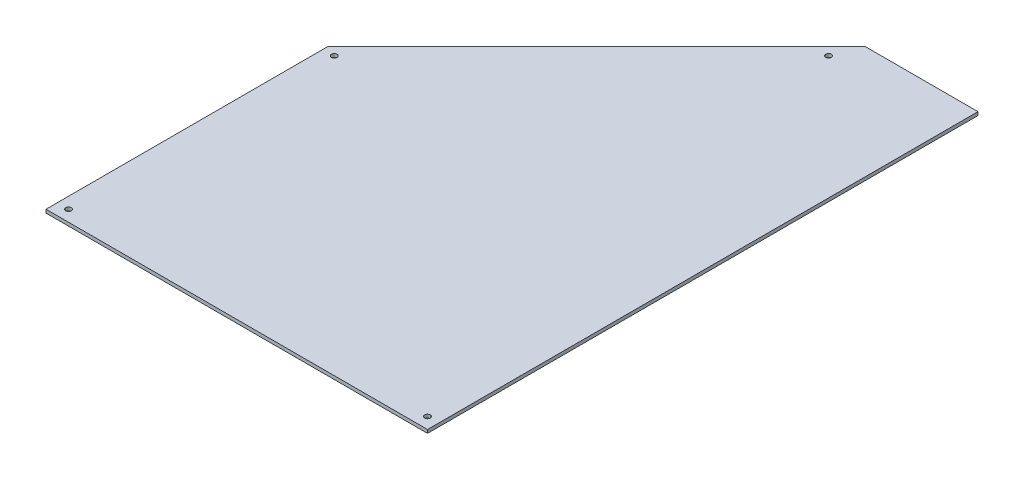
from build123d import *

# Parameters (mm, degrees)
BOSS_EXTRUDE1_DEPTH  = 3
SKETCH3_R            = 2.5
MOUNTING_HOLES_DEPTH = 4


with BuildPart() as part:
    # Sketch2 → Boss-Extrude1 (new body)
    with BuildSketch(Plane(origin=(0, 0, 0), x_dir=(1, 0, 0), z_dir=(0, 1, 0))):
        Polygon((150, 250), (388.61, 488.61), (488.61, 488.61), (488.61, 0), (150, 0), align=None)
    extrude(amount=BOSS_EXTRUDE1_DEPTH)

    # Sketch3 → mounting-holes (cut, through all)
    with BuildSketch(Plane(origin=(0, 3, 0), x_dir=(1, 0, 0), z_dir=(0, 1, 0))):
        with Locations((160, 245.857864376)):
            Circle(SKETCH3_R)
        with Locations((160, 10)):
            Circle(SKETCH3_R)
        with Locations((478.61, 10)):
            Circle(SKETCH3_R)
        with Locations((379.368855681, 465.226720057)):
            Circle(SKETCH3_R)
    extrude(amount=-MOUNTING_HOLES_DEPTH, mode=Mode.SUBTRACT)


solid = part.part
